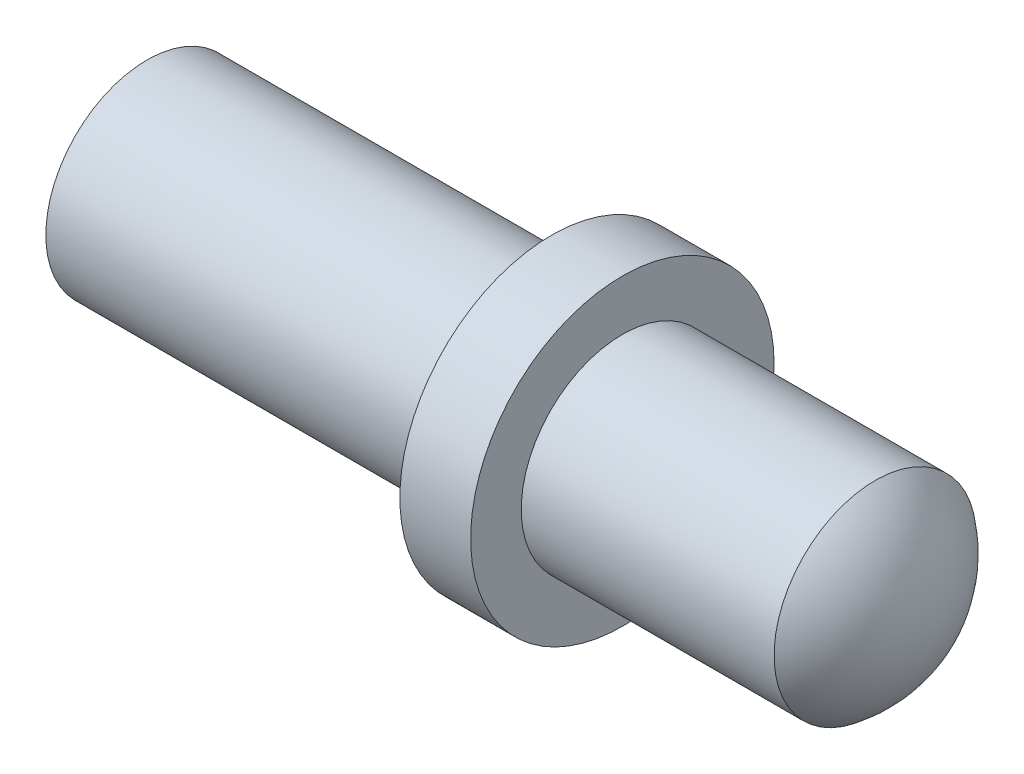
from build123d import *

# Parameters (mm, degrees)
D_ME1_FACE_RADIUS = 2
D_ME1_HEIGHT      = 1


with BuildPart() as part:
    # Esquisse1 → R_volution1 (revolve)
    with BuildSketch(Plane.XY, mode=Mode.PRIVATE) as r_volution1_sk:
        Polygon((0, 0), (0, 2), (8, 2), (8, 3), (9.4, 3), (9.4, 2), (14.4, 2), (14.4, 0), align=None)
    revolve(r_volution1_sk.sketch.rotate(Axis((14.4, 0, 0), (-1, 0, 0)), 90), axis=Axis((14.4, 0, 0), (-1, 0, 0)))  # turned: the seam where the file's is

    # D_me1: a dome of height H over a round flat face of radius A is a cap of a sphere of radius (A * A + H * H) / (2 * H)
    d_me1_r = (D_ME1_FACE_RADIUS * D_ME1_FACE_RADIUS + D_ME1_HEIGHT * D_ME1_HEIGHT) / (2 * D_ME1_HEIGHT)
    d_me1_base = Plane((14.4, 0, 0), z_dir=(1, 0, 0))
    with Locations(d_me1_base.offset(D_ME1_HEIGHT - d_me1_r)):
        d_me1_ball = Sphere(d_me1_r, mode=Mode.PRIVATE)
    add(split(d_me1_ball, bisect_by=d_me1_base, keep=Keep.TOP, mode=Mode.PRIVATE))


solid = part.part
